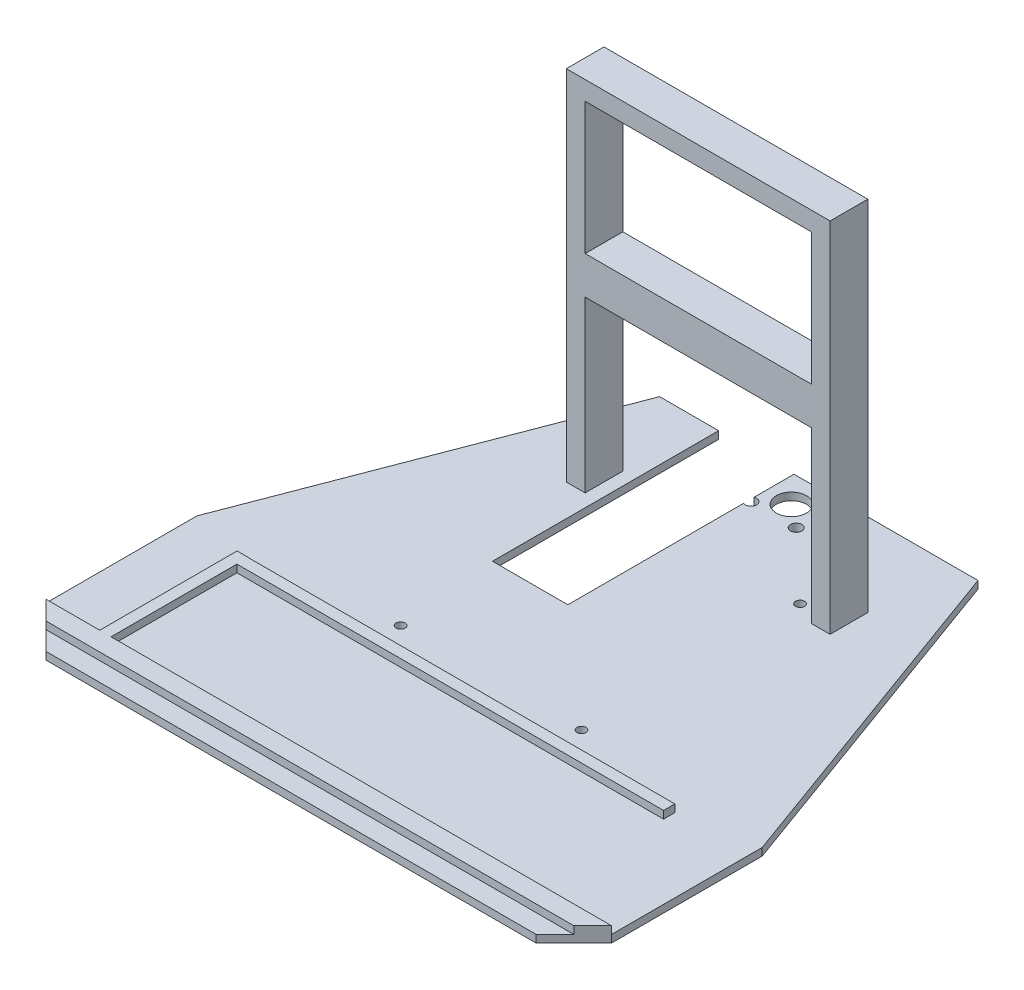
from build123d import *

# Parameters (mm, degrees)
BOSS_EXTRUDE1_DEPTH = 2
BOSS_EXTRUDE2_DEPTH = 2
SKETCH4_W           = 3
SKETCH4_H           = 36.44
BOSS_EXTRUDE3_DEPTH = 2
SKETCH5_W           = 113.22
SKETCH5_H           = 3
BOSS_EXTRUDE4_DEPTH = 2
CUT_EXTRUDE1_REACH  = 4
SKETCH6_R           = 1.2
CUT_EXTRUDE2_REACH  = 4
SKETCH10_R          = 1.5
SKETCH11_W          = 5
SKETCH11_H          = 10
BOSS_EXTRUDE6_DEPTH = 95
SKETCH12_W          = 10
SKETCH12_H          = 5
BOSS_EXTRUDE7_DEPTH = 60
CUT_EXTRUDE3_REACH  = 99
SKETCH13_R          = 4
SKETCH14_W          = 10
SKETCH14_H          = 10
BOSS_EXTRUDE8_DEPTH = 60
CUT_EXTRUDE4_REACH  = 4
SKETCH16_W          = 20
SKETCH16_H          = 60


with BuildPart() as part:
    # Sketch1 → Boss-Extrude1 (new body)
    with BuildSketch(Plane(origin=(0, 0, 0), x_dir=(1, 0, 0), z_dir=(0, 1, 0))):
        Polygon((-76.190879746, -68.876090608), (-65.066970355, -80), (65, -80), (75, -70), (75, -30), (42.284331493, 59.968088394), (-42.212099054, 59.968088394), (-76.190879746, -28.818652669), align=None)
    extrude(amount=BOSS_EXTRUDE1_DEPTH)

    # Sketch2 → Boss-Extrude2 (add)
    with BuildSketch(Plane(origin=(0, 2, 0), x_dir=(1, 0, 0), z_dir=(0, 1, 0))):
        Polygon((-75.066970355, -70), (75, -70), (70, -75), (-70.066970355, -75), align=None)
    extrude(amount=BOSS_EXTRUDE2_DEPTH)

    # Sketch4 → Boss-Extrude3 (add)
    with BuildSketch(Plane(origin=(0, 2, 0), x_dir=(1, 0, 0), z_dir=(0, 1, 0))):
        with Locations((-59.300879746, -51.78)):
            Rectangle(SKETCH4_W, SKETCH4_H)
    extrude(amount=BOSS_EXTRUDE3_DEPTH)

    # Sketch5 → Boss-Extrude4 (add)
    with BuildSketch(Plane(origin=(0, 2, 0), x_dir=(1, 0, 0), z_dir=(0, 1, 0))):
        with Locations((-1.190879746, -35.1)):
            Rectangle(SKETCH5_W, SKETCH5_H)
    extrude(amount=BOSS_EXTRUDE4_DEPTH)

    # Sketch6 → Cut-Extrude1 (cut, up to next)
    with BuildSketch(Plane(origin=(0, 2, 0), x_dir=(1, 0, 0), z_dir=(0, 1, 0)), mode=Mode.PRIVATE) as cut_extrude1_sk1:
        with Locations((-23.96388378, 31)):
            Circle(SKETCH6_R)
    cut_extrude1_tool1 = extrude(cut_extrude1_sk1.sketch, amount=-CUT_EXTRUDE1_REACH, mode=Mode.PRIVATE) & part.part
    add(cut_extrude1_tool1.solids().sort_by_distance((-23.963884, 2, -31))[0], mode=Mode.SUBTRACT)
    # Sketch6 → Cut-Extrude1 (cut, up to next)
    with BuildSketch(Plane(origin=(0, 2, 0), x_dir=(1, 0, 0), z_dir=(0, 1, 0)), mode=Mode.PRIVATE) as cut_extrude1_sk2:
        with Locations((24.03611622, 31)):
            Circle(SKETCH6_R)
    cut_extrude1_tool2 = extrude(cut_extrude1_sk2.sketch, amount=-CUT_EXTRUDE1_REACH, mode=Mode.PRIVATE) & part.part
    add(cut_extrude1_tool2.solids().sort_by_distance((24.036116, 2, -31))[0], mode=Mode.SUBTRACT)
    # Sketch6 → Cut-Extrude1 (cut, up to next)
    with BuildSketch(Plane(origin=(0, 2, 0), x_dir=(1, 0, 0), z_dir=(0, 1, 0)), mode=Mode.PRIVATE) as cut_extrude1_sk3:
        with Locations((-23.96388378, -27)):
            Circle(SKETCH6_R)
    cut_extrude1_tool3 = extrude(cut_extrude1_sk3.sketch, amount=-CUT_EXTRUDE1_REACH, mode=Mode.PRIVATE) & part.part
    add(cut_extrude1_tool3.solids().sort_by_distance((-23.963884, 2, 27))[0], mode=Mode.SUBTRACT)
    # Sketch6 → Cut-Extrude1 (cut, up to next)
    with BuildSketch(Plane(origin=(0, 2, 0), x_dir=(1, 0, 0), z_dir=(0, 1, 0)), mode=Mode.PRIVATE) as cut_extrude1_sk4:
        with Locations((24.03611622, -27)):
            Circle(SKETCH6_R)
    cut_extrude1_tool4 = extrude(cut_extrude1_sk4.sketch, amount=-CUT_EXTRUDE1_REACH, mode=Mode.PRIVATE) & part.part
    add(cut_extrude1_tool4.solids().sort_by_distance((24.036116, 2, 27))[0], mode=Mode.SUBTRACT)

    # Sketch10 → Cut-Extrude2 (cut, up to next)
    with BuildSketch(Plane(origin=(0, 2, 0), x_dir=(1, 0, 0), z_dir=(0, 1, 0)), mode=Mode.PRIVATE) as cut_extrude2_sk1:
        with Locations((-5.96388378, 47.968088394)):
            Circle(SKETCH10_R)
    cut_extrude2_tool1 = extrude(cut_extrude2_sk1.sketch, amount=-CUT_EXTRUDE2_REACH, mode=Mode.PRIVATE) & part.part
    add(cut_extrude2_tool1.solids().sort_by_distance((-5.963884, 2, -47.968088))[0], mode=Mode.SUBTRACT)
    # Sketch10 → Cut-Extrude2 (cut, up to next)
    with BuildSketch(Plane(origin=(0, 2, 0), x_dir=(1, 0, 0), z_dir=(0, 1, 0)), mode=Mode.PRIVATE) as cut_extrude2_sk2:
        with Locations((6.03611622, 47.968088394)):
            Circle(SKETCH10_R)
    cut_extrude2_tool2 = extrude(cut_extrude2_sk2.sketch, amount=-CUT_EXTRUDE2_REACH, mode=Mode.PRIVATE) & part.part
    add(cut_extrude2_tool2.solids().sort_by_distance((6.036116, 2, -47.968088))[0], mode=Mode.SUBTRACT)

    # Sketch11 → Boss-Extrude6 (add)
    with BuildSketch(Plane(origin=(0, 2, 0), x_dir=(1, 0, 0), z_dir=(0, 1, 0))):
        with Locations((-32.46388378, 32.968088394)):
            Rectangle(SKETCH11_W, SKETCH11_H)
        with Locations((32.53611622, 32.968088394)):
            Rectangle(SKETCH11_W, SKETCH11_H)
    extrude(amount=BOSS_EXTRUDE6_DEPTH)

    # Sketch12 → Boss-Extrude7 (add)
    with BuildSketch(Plane(origin=(-29.96388378, 0, 0), x_dir=(0, 0, -1), z_dir=(1, 0, 0))):
        with Locations((32.968088394, 94.5)):
            Rectangle(SKETCH12_W, SKETCH12_H)
    extrude(amount=BOSS_EXTRUDE7_DEPTH)

    # Sketch13 → Cut-Extrude3 (cut, up to next)
    with BuildSketch(Plane(origin=(0, 97, 0), x_dir=(1, 0, 0), z_dir=(0, 1, 0)), mode=Mode.PRIVATE) as cut_extrude3_sk1:
        with Locations((0.03611622, 52.704663647)):
            Circle(SKETCH13_R)
    cut_extrude3_tool1 = extrude(cut_extrude3_sk1.sketch, amount=-CUT_EXTRUDE3_REACH, mode=Mode.PRIVATE) & part.part
    add(cut_extrude3_tool1.solids().sort_by_distance((0.036116, 97, -52.704664))[0], mode=Mode.SUBTRACT)

    # Sketch14 → Boss-Extrude8 (add)
    with BuildSketch(Plane(origin=(-29.96388378, 0, 0), x_dir=(0, 0, -1), z_dir=(1, 0, 0))):
        with Locations((32.968088394, 52)):
            Rectangle(SKETCH14_W, SKETCH14_H)
    extrude(amount=BOSS_EXTRUDE8_DEPTH)

    # Sketch16 → Cut-Extrude4 (cut, up to next)
    with BuildSketch(Plane(origin=(0, 2, 0), x_dir=(1, 0, 0), z_dir=(0, 1, 0)), mode=Mode.PRIVATE) as cut_extrude4_sk1:
        with Locations((-16.550598938, 29.968088394)):
            Rectangle(SKETCH16_W, SKETCH16_H)
    cut_extrude4_tool1 = extrude(cut_extrude4_sk1.sketch, amount=-CUT_EXTRUDE4_REACH, mode=Mode.PRIVATE) & part.part
    add(cut_extrude4_tool1.solids().sort_by_distance((-16.550599, 2, -29.968088))[0], mode=Mode.SUBTRACT)


solid = part.part
